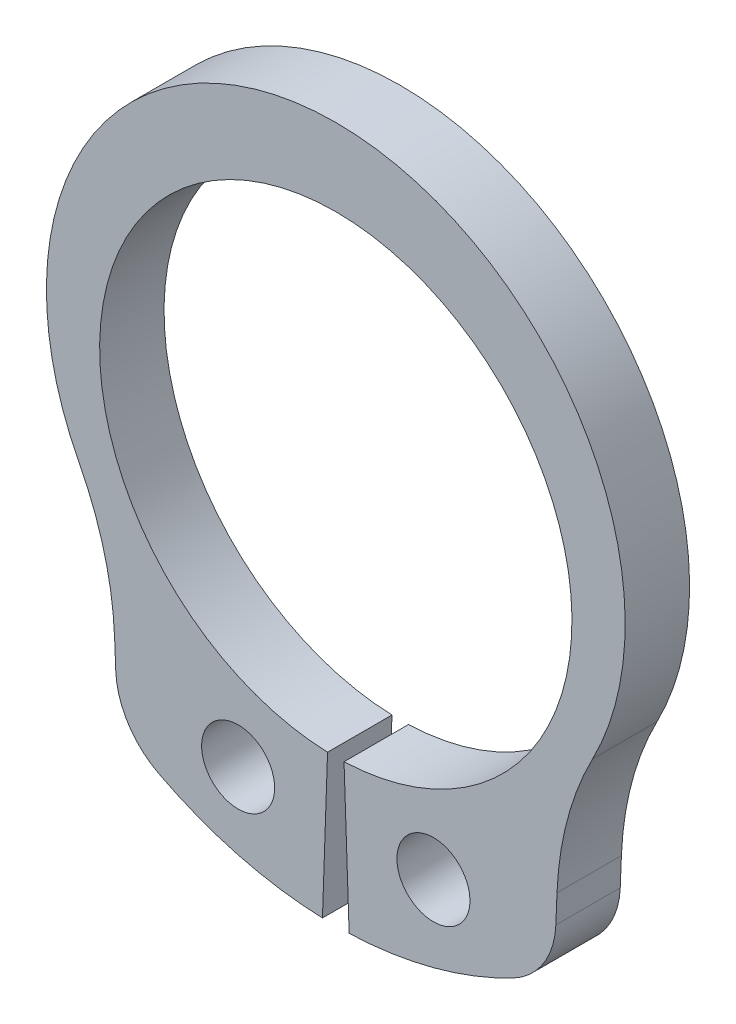
from build123d import *

# Parameters (mm, degrees)
SKETCH2_R           = 0.85
BOSS_EXTRUDE1_DEPTH = 0.75
FILLET1_R           = 7.400617123
FILLET2_R           = 1.850154281


with BuildPart() as part:
    # Sketch2 → Boss-Extrude1 (new body, symmetric)
    with BuildSketch(Plane.XY):
        with BuildLine():
            Line((-5.084030917, -7.311581435), (-5.231445397, -3.68673013))
            ThreePointArc((-5.231445397, -3.68673013), (-6.08432946, 3.458247986), (0, 7.3))
            Line((0, 7.3), (0, 5.5))
            ThreePointArc((0, 5.5), (-5.499162323, 0.095988235), (-0.191947232, -5.496649549))
            Line((-0.191947232, -5.496649549), (-0.310794848, -8.9))
            ThreePointArc((-0.310794848, -8.9), (-2.811904096, -8.449839572), (-5.084030917, -7.311581435))
        make_face()
        with Locations((-2.274269541, -6.834234779)):
            Circle(SKETCH2_R, mode=Mode.SUBTRACT)
    extrude(amount=BOSS_EXTRUDE1_DEPTH, both=True)

    # Fillet1
    fillet1_edges = [part.edges().sort_by_distance(p)[0] for p in [
        (-5.231445397, -3.68673013, 0),
    ]]
    fillet(fillet1_edges, radius=FILLET1_R)

    # Fillet2
    fillet2_edges = [part.edges().sort_by_distance(p)[0] for p in [
        (-5.084030917, -7.311581435, 0),
    ]]
    fillet(fillet2_edges, radius=FILLET2_R)

    # Mirror1: part across plane


with BuildPart() as part_1:
    add(part.part)
    add(part.part.mirror(Plane(origin=(0, 7.3, 0.75), x_dir=(0, 0, 1), z_dir=(-1, 0, 0))))


solid = part_1.part
